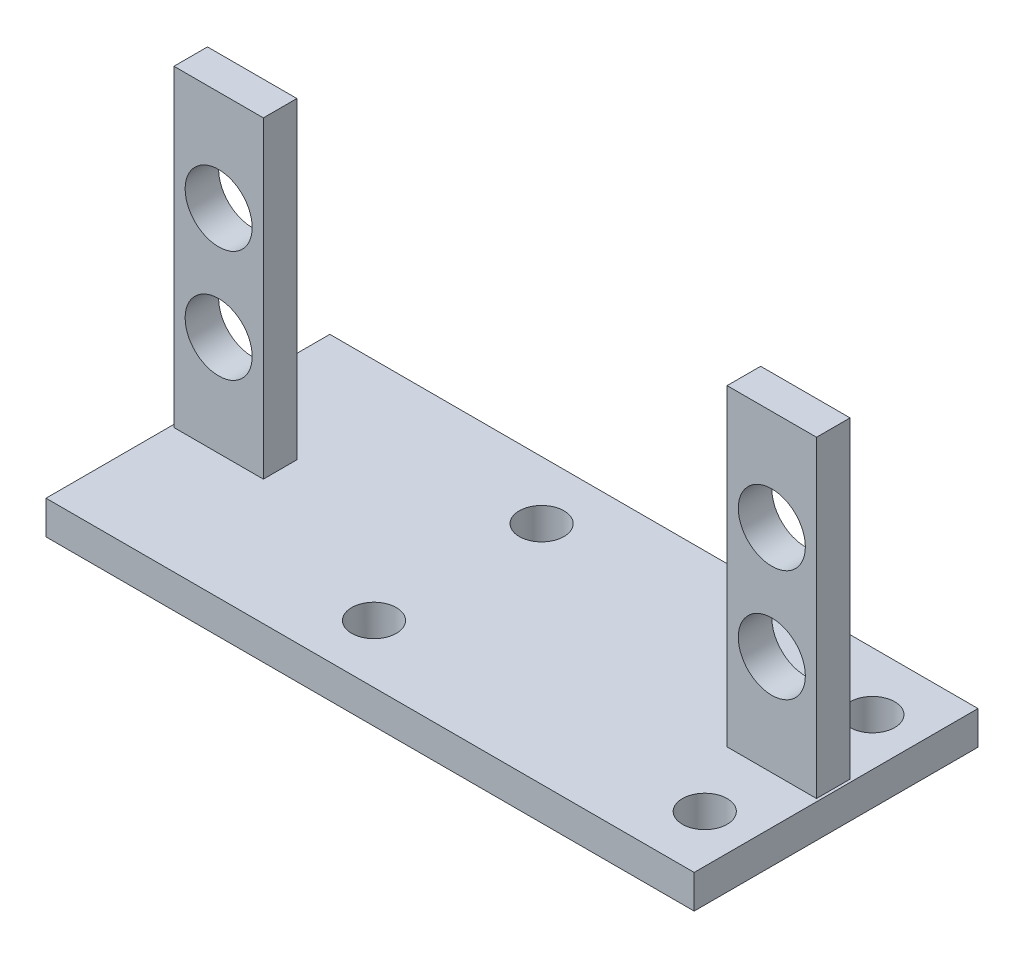
from build123d import *

# Parameters (mm, degrees)
SKETCH_1_W          = 58
SKETCH_1_H          = 25.4
EXTRUDE_1_DEPTH     = 3
SKETCH_2_W          = 8
SKETCH_2_H          = 3
EXTRUDE_2_DEPTH     = 28
SKETCH_3_R          = 3
CUT_EXTRUDE_1_DEPTH = 12
SKETCH_4_R          = 2
CUT_EXTRUDE_2_DEPTH = 22
SKETCH_8_W          = 8
SKETCH_8_H          = 3
CUT_EXTRUDE_3_DEPTH = 28


with BuildPart() as part:
    # 草图1 → 凸台-拉伸1 (new body)
    with BuildSketch(Plane(origin=(0, 0, 0), x_dir=(1, 0, 0), z_dir=(0, 1, 0))):
        Rectangle(SKETCH_1_W, SKETCH_1_H)
    extrude(amount=EXTRUDE_1_DEPTH)

    # 草图2 → 凸台-拉伸2 (add)
    with BuildSketch(Plane(origin=(0, 3, 0), x_dir=(1, 0, 0), z_dir=(0, 1, 0))):
        with Locations((-24.75, 11.2)):
            Rectangle(SKETCH_2_W, SKETCH_2_H)
        with Locations((24.75, 11.2)):
            Rectangle(SKETCH_2_W, SKETCH_2_H)
        with Locations((-24.75, 0)):
            Rectangle(SKETCH_2_W, SKETCH_2_H)
        with Locations((24.75, 0)):
            Rectangle(SKETCH_2_W, SKETCH_2_H)
    extrude(amount=EXTRUDE_2_DEPTH)

    # 草图3 → 切除-拉伸1 (cut, symmetric)
    with BuildSketch(Plane.XY.offset(-9.7)):
        with Locations((-24.75, 12)):
            Circle(SKETCH_3_R)
        with Locations((-24.75, 22)):
            Circle(SKETCH_3_R)
        with Locations((24.75, 12)):
            Circle(SKETCH_3_R)
        with Locations((24.75, 22)):
            Circle(SKETCH_3_R)
    extrude(amount=CUT_EXTRUDE_1_DEPTH, both=True, mode=Mode.SUBTRACT)

    # 草图4 → 切除-拉伸2 (cut)
    with BuildSketch(Plane(origin=(0, 3, 0), x_dir=(1, 0, 0), z_dir=(0, 1, 0))):
        with Locations((24.75, -7.5)):
            Circle(SKETCH_4_R)
        with Locations((24.75, 7.5)):
            Circle(SKETCH_4_R)
        with Locations((-4.85, 7.5)):
            Circle(SKETCH_4_R)
        with Locations((-4.85, -7.5)):
            Circle(SKETCH_4_R)
    extrude(amount=-CUT_EXTRUDE_2_DEPTH, mode=Mode.SUBTRACT)

    # 草图8 → 切除-拉伸3 (cut)
    with BuildSketch(Plane(origin=(0, 31, 0), x_dir=(1, 0, 0), z_dir=(0, 1, 0))):
        with Locations((-24.75, 11.2)):
            Rectangle(SKETCH_8_W, SKETCH_8_H)
        with Locations((24.75, 11.2)):
            Rectangle(SKETCH_8_W, SKETCH_8_H)
    extrude(amount=-CUT_EXTRUDE_3_DEPTH, mode=Mode.SUBTRACT)


solid = part.part
